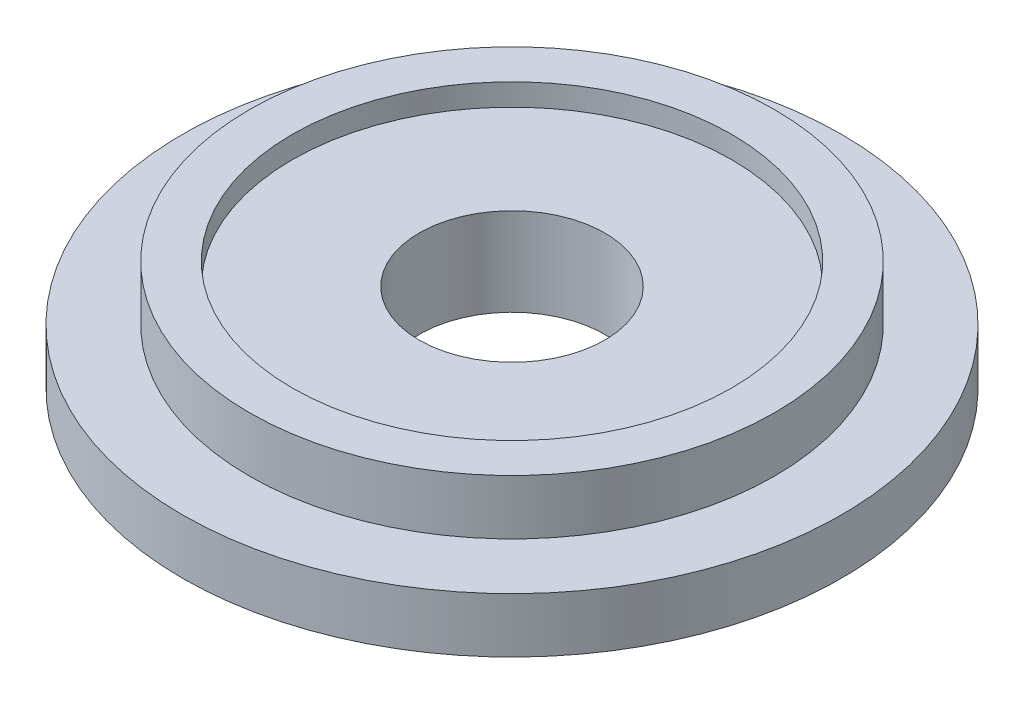
from build123d import *

# Parameters (mm, degrees)
CROQUIS1_R              = 23.9
CROQUIS1_R_2            = 8.45
SALIENTE_EXTRUIR1_DEPTH = 5
SALIENTE_EXTRUIR2_START = -5
CROQUIS1_3_R            = 30
CROQUIS1_3_R_2          = 8.45
SALIENTE_EXTRUIR2_DEPTH = 5
CROQUIS2_R              = 20
CORTAR_EXTRUIR1_DEPTH   = 2


with BuildPart() as part:
    # Croquis1 → Saliente-Extruir1 (new body)
    with BuildSketch(Plane(origin=(0, 0, 0), x_dir=(1, 0, 0), z_dir=(0, 1, 0))):
        Circle(CROQUIS1_R)
        Circle(CROQUIS1_R_2, mode=Mode.SUBTRACT)
    extrude(amount=SALIENTE_EXTRUIR1_DEPTH)

    # Croquis1_3 → Saliente-Extruir2 (add)
    with BuildSketch(Plane(origin=(0, 0, 0), x_dir=(1, 0, 0), z_dir=(0, 1, 0)).offset(SALIENTE_EXTRUIR2_START)):
        Circle(CROQUIS1_3_R)
        Circle(CROQUIS1_3_R_2, mode=Mode.SUBTRACT)
    extrude(amount=SALIENTE_EXTRUIR2_DEPTH)

    # Croquis2 → Cortar-Extruir1 (cut)
    with BuildSketch(Plane(origin=(0, 5, 0), x_dir=(1, 0, 0), z_dir=(0, 1, 0))):
        Circle(CROQUIS2_R)
    extrude(amount=-CORTAR_EXTRUIR1_DEPTH, mode=Mode.SUBTRACT)


solid = part.part
